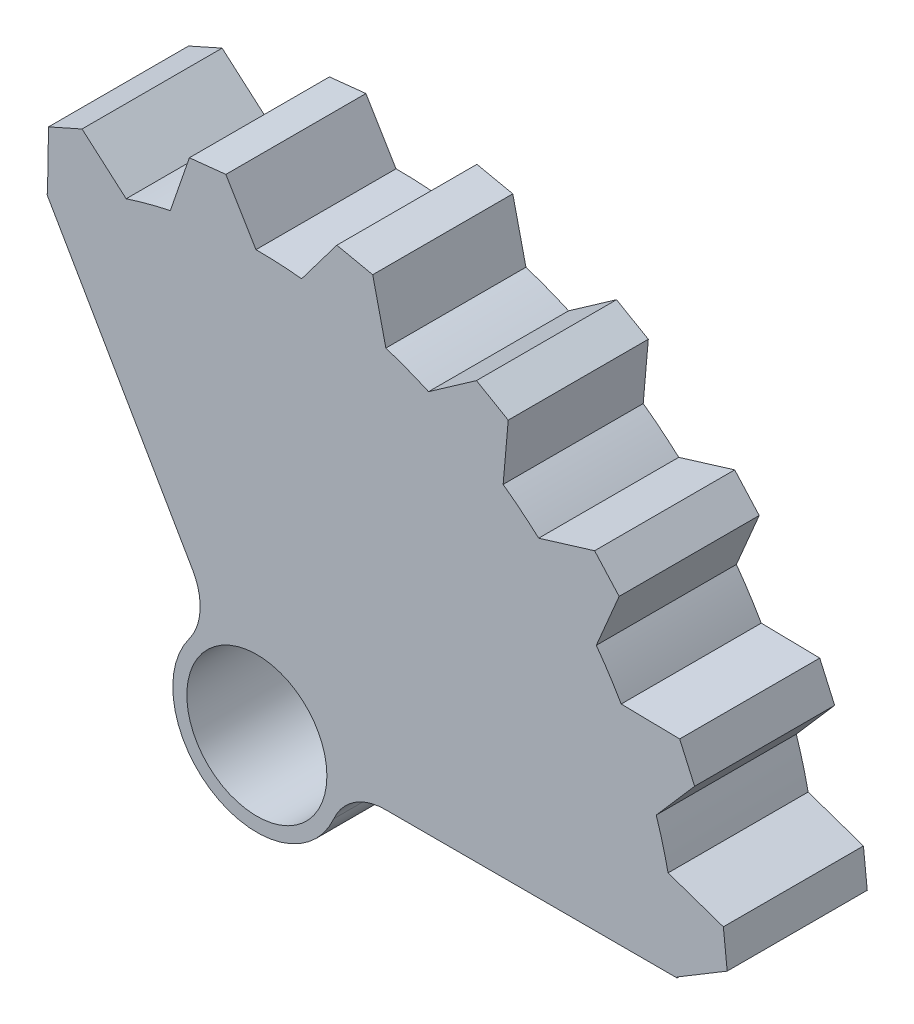
from build123d import *

# Parameters (mm, degrees)
SKETCH1_R           = 2.5
BOSS_EXTRUDE1_DEPTH = 5
FILLET1_R           = 2
FILLET2_R           = 2


with BuildPart() as part:
    # Sketch1 → Boss-Extrude1 (new body)
    with BuildSketch(Plane.XY):
        with BuildLine():
            Line((-7.5, 12.990381057), (-1.5, 2.598076211))
            ThreePointArc((-1.5, 2.598076211), (-1.5, -2.598076211), (3, 0))
            Line((3, 0), (15, 0))
            ThreePointArc((15, 0), (14.999991842, 0.01564381), (14.999967369, 0.031287604))
            Line((14.999967369, 0.031287604), (16.788955727, 1.106220256))
            Line((16.788955727, 1.106220256), (16.652072887, 2.408573483))
            Line((16.652072887, 2.408573483), (14.761035736, 3.059709792))
            Line((14.761035736, 3.059709792), (14.678687152, 3.088064683))
            ThreePointArc((14.678687152, 3.088064683), (14.488887394, 3.882285677), (14.25614831, 4.665001112))
            Line((14.25614831, 4.665001112), (15.625404887, 6.24015062))
            Line((15.625404887, 6.24015062), (15.09277229, 7.43646302))
            Line((15.09277229, 7.43646302), (13.0930769, 7.471367833))
            Line((13.0930769, 7.471367833), (13.0059966, 7.472887825))
            ThreePointArc((13.0059966, 7.472887825), (12.580058519, 8.169585525), (12.116838125, 8.842071808))
            Line((12.116838125, 8.842071808), (12.932330549, 10.763251564))
            Line((12.932330549, 10.763251564), (12.056085985, 11.736419743))
            Line((12.056085985, 11.736419743), (10.143476473, 11.151676334))
            Line((10.143476473, 11.151676334), (10.060188482, 11.12621264))
            ThreePointArc((10.060188482, 11.12621264), (9.439805866, 11.657189422), (8.791447401, 12.153618909))
            Line((8.791447401, 12.153618909), (8.973349591, 14.232770453))
            Line((8.973349591, 14.232770453), (7.839265983, 14.887533929))
            Line((7.839265983, 14.887533929), (6.200961894, 13.740381057))
            Line((6.200961894, 13.740381057), (6.129619023, 13.69042624))
            ThreePointArc((6.129619023, 13.69042624), (5.375519243, 14.003706397), (4.605488553, 14.275485112))
            Line((4.605488553, 14.275485112), (4.135994655, 16.309086604))
            Line((4.135994655, 16.309086604), (2.855084007, 16.581352567))
            Line((2.855084007, 16.581352567), (1.651453961, 14.984081547))
            Line((1.651453961, 14.984081547), (1.599039745, 14.914525534))
            ThreePointArc((1.599039745, 14.914525534), (0.785039344, 14.979443021), (-0.031287604, 14.999967369))
            Line((-0.031287604, 14.999967369), (-1.106220256, 16.788955727))
            Line((-1.106220256, 16.788955727), (-2.408573483, 16.652072887))
            Line((-2.408573483, 16.652072887), (-3.059709792, 14.761035736))
            Line((-3.059709792, 14.761035736), (-3.088064683, 14.678687152))
            ThreePointArc((-3.088064683, 14.678687152), (-3.882285677, 14.488887394), (-4.665001112, 14.25614831))
            Line((-4.665001112, 14.25614831), (-6.24015062, 15.625404887))
            Line((-6.24015062, 15.625404887), (-7.43646302, 15.09277229))
            Line((-7.43646302, 15.09277229), (-7.471367833, 13.0930769))
            Line((-7.471367833, 13.0930769), (-7.472887825, 13.0059966))
            ThreePointArc((-7.472887825, 13.0059966), (-7.486447984, 12.998195897), (-7.5, 12.990381057))
        make_face()
        Circle(SKETCH1_R, mode=Mode.SUBTRACT)
    extrude(amount=BOSS_EXTRUDE1_DEPTH)

    # Fillet1
    fillet1_edges = [part.edges().sort_by_distance(p)[0] for p in [
        (-1.5, 2.598076211, 2.5),
    ]]
    fillet(fillet1_edges, radius=FILLET1_R)

    # Fillet2
    fillet2_edges = [part.edges().sort_by_distance(p)[0] for p in [
        (3, 0, 2.5),
    ]]
    fillet(fillet2_edges, radius=FILLET2_R)


solid = part.part
